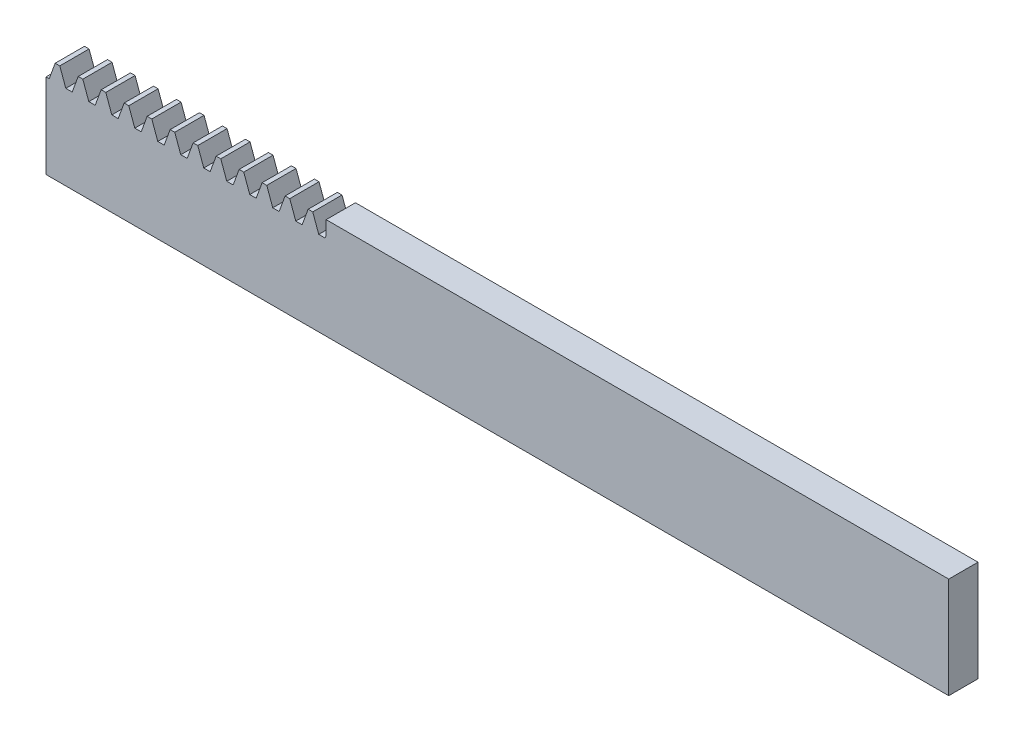
from build123d import *

# Parameters (mm, degrees)
BLANKSKE_W              = 185
BLANKSKE_H              = 21.7
BLANK_DEPTH             = 6
TOOTHCUTSIM_DEPTH       = 187.364937689
TEETHCUTS_COUNT         = 40
TEETHCUTS_PITCH         = 4.712388975
ESQUISSE2_W             = 127.585231164
ESQUISSE2_H             = 3.375
BOSS_EXTRU_1_DEPTH      = 6
ESQUISSE3_W             = 185
ESQUISSE3_H             = 1
ENL_V_MAT_EXTRU_1_DEPTH = 6


with BuildPart() as part:
    # BlankSke → Blank (new body)
    with BuildSketch(Plane.XY):
        with Locations((92.5, 10.85)):
            Rectangle(BLANKSKE_W, BLANKSKE_H)
    extrude(amount=-BLANK_DEPTH)

    # TooCutSkeSim → ToothCutSim (cut, through all)
    with BuildSketch(Plane.XY):
        Polygon((0.654653055, 18.325), (-0.654653055, 18.325), (-1.892297439, 21.7254), (1.892297439, 21.7254), align=None)
    toothcutsim = extrude(amount=-TOOTHCUTSIM_DEPTH, mode=Mode.SUBTRACT)

    # TeethCuts: ToothCutSim ×40
    with Locations(*[(i * TEETHCUTS_PITCH, 0, 0) for i in range(1, TEETHCUTS_COUNT)]):
        add(toothcutsim, mode=Mode.SUBTRACT)

    # Esquisse2 → Boss.-Extru.1 (add)
    with BuildSketch(Plane.XY):
        with Locations((121.207384418, 20.0125)):
            Rectangle(ESQUISSE2_W, ESQUISSE2_H)
    extrude(amount=-BOSS_EXTRU_1_DEPTH)

    # Esquisse3 → Enlèv. mat.-Extru.1 (cut)
    with BuildSketch(Plane.XY):
        with Locations((92.5, 0.5)):
            Rectangle(ESQUISSE3_W, ESQUISSE3_H)
    extrude(amount=-ENL_V_MAT_EXTRU_1_DEPTH, mode=Mode.SUBTRACT)


solid = part.part
